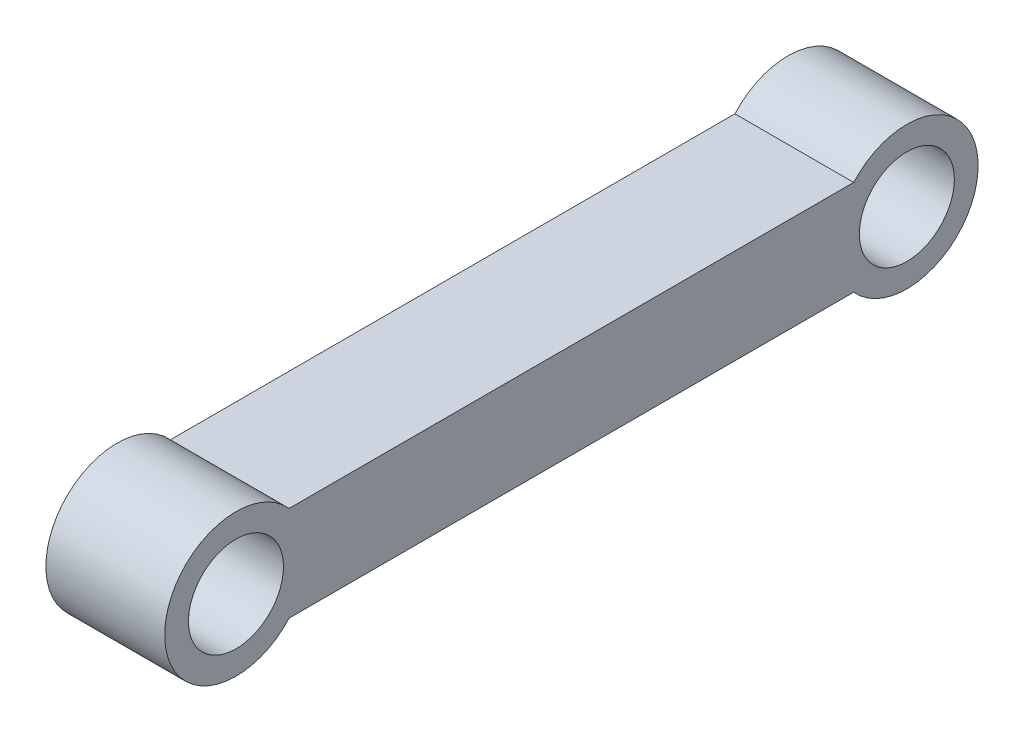
from build123d import *

# Parameters (mm, degrees)
LINKFRAME_R         = 40
BOSS_EXTRUDE1_DEPTH = 100


with BuildPart() as part:
    # LinkFrame → Boss-Extrude1 (new body)
    with BuildSketch(Plane(origin=(0, 0, 0), x_dir=(0, 0, -1), z_dir=(1, 0, 0))):
        with BuildLine():
            Line((-260.24417903, -186.263273145), (214.93310187, -186.263273145))
            ThreePointArc((214.93310187, -186.263273145), (319.65446142, -226.263273145), (214.93310187, -266.263273145))
            Line((214.93310187, -266.263273145), (-260.24417903, -266.263273145))
            ThreePointArc((-260.24417903, -266.263273145), (-364.96553858, -226.263273145), (-260.24417903, -186.263273145))
        make_face()
        with Locations((-304.96553858, -226.263273145)):
            Circle(LINKFRAME_R, mode=Mode.SUBTRACT)
        with Locations((259.65446142, -226.263273145)):
            Circle(LINKFRAME_R, mode=Mode.SUBTRACT)
    extrude(amount=BOSS_EXTRUDE1_DEPTH)


solid = part.part
